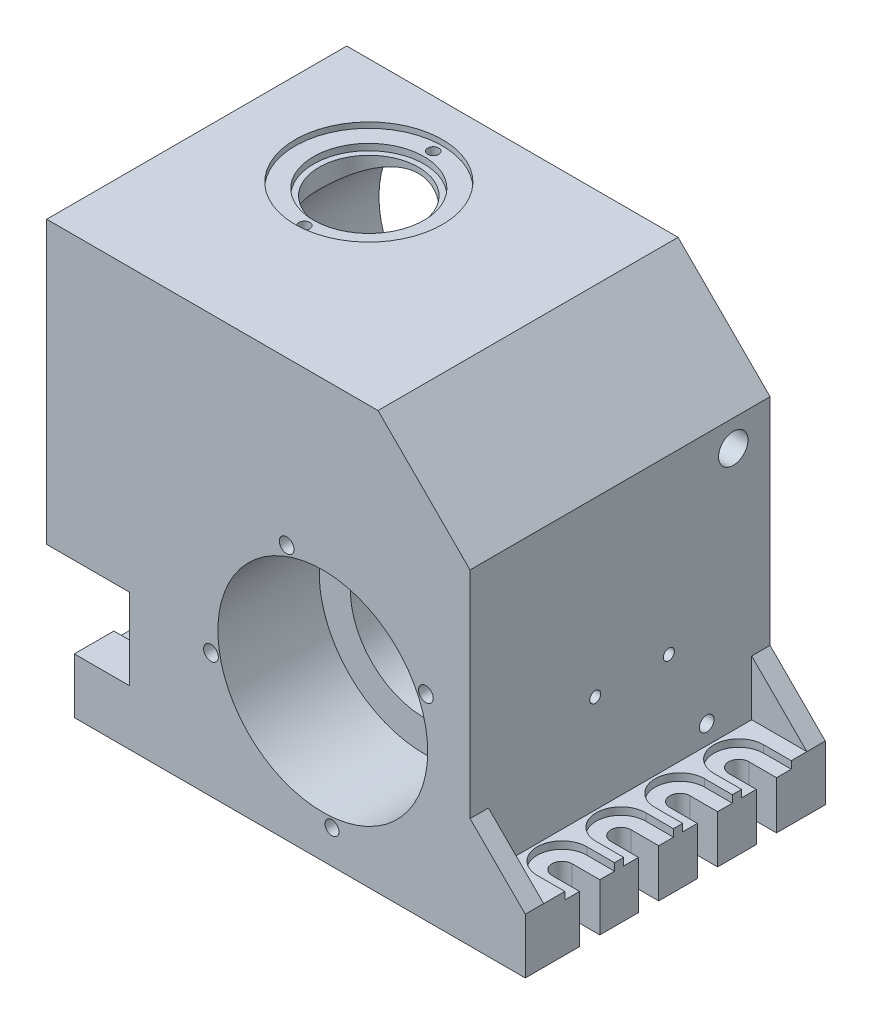
from build123d import *

# Parameters (mm, degrees)
EXTRUDE_1_DEPTH           = 163
SKETCH_2_W                = 143
SKETCH_2_H                = 30
CUT_EXTRUDE_1_DEPTH       = 30
SKETCH_3_W                = 11
SKETCH_3_H                = 30
CUT_EXTRUDE_2_DEPTH       = 15
SKETCH_4_R                = 5.5
CUT_EXTRUDE_3_DEPTH       = 40
CUT_EXTRUDE_4_DEPTH       = 4
SKETCH_6_R                = 40
CUT_EXTRUDE_5_DEPTH       = 248
SKETCH_7_R                = 57
CUT_EXTRUDE_6_DEPTH       = 55
SKETCH_8_R                = 4
SKETCH_8_R_2              = 3.785558093
CUT_EXTRUDE_7_DEPTH       = 18
SKETCH_10_R               = 64.5
CUT_EXTRUDE_8_DEPTH       = 54
SKETCH_11_R               = 42.5
CUT_EXTRUDE_9_DEPTH       = 103
SKETCH_12_R               = 10
CUT_EXTRUDE_10_DEPTH      = 44
SKETCH_13_R               = 21.5
CUT_EXTRUDE_11_DEPTH      = 30
SKETCH_14_R               = 17.5
CUT_EXTRUDE_12_DEPTH      = 11
SKETCH_15_W               = 30
SKETCH_15_H               = 30
EXTRUDE_2_DEPTH           = 163
SKETCH_16_R               = 44.5
CUT_EXTRUDE_13_DEPTH      = 16
SKETCH_17_R               = 52.5
CUT_EXTRUDE_14_DEPTH      = 16
CUT_EXTRUDE_14_DEPTH_BACK = 82
SKETCH_18_R               = 21.5
CUT_EXTRUDE_15_DEPTH      = 29
SKETCH_19_R               = 17.5
CUT_EXTRUDE_16_DEPTH      = 11
SKETCH_20_R               = 10
CUT_EXTRUDE_17_DEPTH      = 3
SKETCH_21_R               = 4
CUT_EXTRUDE_18_DEPTH      = 9
SKETCH_22_R               = 4.14
CUT_EXTRUDE_19_DEPTH      = 10
CUT_EXTRUDE_20_DEPTH      = 120
FILLET_1_R                = 15
SKETCH_24_R               = 27
CUT_EXTRUDE_21_DEPTH      = 30
SKETCH_25_R               = 30
CUT_EXTRUDE_22_DEPTH      = 6.5
SKETCH_26_R               = 40
CUT_EXTRUDE_23_DEPTH      = 3
SKETCH_27_R               = 3
CUT_EXTRUDE_24_DEPTH      = 8
SKETCH_28_R               = 3
CUT_EXTRUDE_25_DEPTH      = 8
SKETCH_29_R               = 4
CUT_EXTRUDE_26_DEPTH      = 37
SKETCH_30_R               = 8
CUT_EXTRUDE_27_DEPTH      = 48


with BuildPart() as part:
    # 草图1 → 凸台-拉伸1 (new body)
    with BuildSketch(Plane.XY):
        Polygon((110, -80), (-105, -80), (-105, -6), (-150, -6), (-150, 147), (30, 147), (80, 97), (80, -20), (110, -50), align=None)
    extrude(amount=EXTRUDE_1_DEPTH)

    # 草图2 → 切除-拉伸1 (cut)
    with BuildSketch(Plane(origin=(110, 0, 0), x_dir=(0, 0, -1), z_dir=(1, 0, 0))):
        with Locations((-81.5, -35)):
            Rectangle(SKETCH_2_W, SKETCH_2_H)
    extrude(amount=-CUT_EXTRUDE_1_DEPTH, mode=Mode.SUBTRACT)

    # 草图3 → 切除-拉伸2 (cut)
    with BuildSketch(Plane(origin=(110, 0, 0), x_dir=(0, 0, -1), z_dir=(1, 0, 0))):
        with Locations((-32, -65)):
            Rectangle(SKETCH_3_W, SKETCH_3_H)
        with Locations((-64, -65)):
            Rectangle(SKETCH_3_W, SKETCH_3_H)
        with Locations((-96, -65)):
            Rectangle(SKETCH_3_W, SKETCH_3_H)
        with Locations((-128, -65)):
            Rectangle(SKETCH_3_W, SKETCH_3_H)
    cut_extrude_2 = extrude(amount=-CUT_EXTRUDE_2_DEPTH, mode=Mode.SUBTRACT)

    # 草图4 → 切除-拉伸3 (cut)
    with BuildSketch(Plane(origin=(0, -50, 0), x_dir=(1, 0, 0), z_dir=(0, 1, 0))):
        with Locations((95, -32)):
            Circle(SKETCH_4_R)
        with Locations((95, -64)):
            Circle(SKETCH_4_R)
        with Locations((95, -96)):
            Circle(SKETCH_4_R)
        with Locations((95, -128)):
            Circle(SKETCH_4_R)
    cut_extrude_3 = extrude(amount=-CUT_EXTRUDE_3_DEPTH, mode=Mode.SUBTRACT)

    # 草图5 → 切除-拉伸4 (cut)
    with BuildSketch(Plane(origin=(0, -50, 0), x_dir=(1, 0, 0), z_dir=(0, 1, 0))):
        with BuildLine():
            Line((95, -77.5), (110, -77.5))
            Line((110, -77.5), (110, -50.5))
            Line((110, -50.5), (95, -50.5))
            ThreePointArc((95, -50.5), (81.5, -64), (95, -77.5))
        make_face()
        with BuildLine():
            Line((95, -45.5), (110, -45.5))
            Line((110, -45.5), (110, -18.5))
            Line((110, -18.5), (95, -18.5))
            ThreePointArc((95, -18.5), (81.5, -32), (95, -45.5))
        make_face()
        with BuildLine():
            Line((95, -109.5), (110, -109.5))
            Line((110, -109.5), (110, -82.5))
            Line((110, -82.5), (95, -82.5))
            ThreePointArc((95, -82.5), (81.5, -96), (95, -109.5))
        make_face()
        with BuildLine():
            Line((95, -141.5), (110, -141.5))
            Line((110, -141.5), (110, -114.5))
            Line((110, -114.5), (95, -114.5))
            ThreePointArc((95, -114.5), (81.5, -128), (95, -141.5))
        make_face()
    cut_extrude_4 = extrude(amount=-CUT_EXTRUDE_4_DEPTH, mode=Mode.SUBTRACT)

    # 草图6 → 切除-拉伸5 (cut)
    with BuildSketch(Plane.XY.offset(163)):
        Circle(SKETCH_6_R)
    extrude(amount=-CUT_EXTRUDE_5_DEPTH, mode=Mode.SUBTRACT)

    # 草图7 → 切除-拉伸6 (cut)
    with BuildSketch(Plane.XY.offset(163)):
        Circle(SKETCH_7_R)
    extrude(amount=-CUT_EXTRUDE_6_DEPTH, mode=Mode.SUBTRACT)

    # 草图8 → 切除-拉伸7 (cut)
    with BuildSketch(Plane.XY.offset(163)):
        with Locations((-19.633415616, 58.809259401)):
            Circle(SKETCH_8_R)
        with Locations((56.013926946, 26.578938807)):
            Circle(SKETCH_8_R)
        with Locations((-60.747020427, -12.401593014)):
            Circle(SKETCH_8_R)
        with Locations((4.98892726, -61.798953104)):
            Circle(SKETCH_8_R_2)
    extrude(amount=-CUT_EXTRUDE_7_DEPTH, mode=Mode.SUBTRACT)

    # 草图10 → 切除-拉伸8 (cut)
    with BuildSketch(Plane(origin=(0, 0, 0), x_dir=(-1, 0, 0), z_dir=(0, 0, -1))):
        Circle(SKETCH_10_R)
    extrude(amount=-CUT_EXTRUDE_8_DEPTH, mode=Mode.SUBTRACT)

    # 草图11 → 切除-拉伸9 (cut)
    with BuildSketch(Plane(origin=(0, 0, 0), x_dir=(-1, 0, 0), z_dir=(0, 0, -1))):
        with Locations((0, 85)):
            Circle(SKETCH_11_R)
    extrude(amount=-CUT_EXTRUDE_9_DEPTH, mode=Mode.SUBTRACT)

    # 草图12 → 切除-拉伸10 (cut)
    with BuildSketch(Plane(origin=(0, 0, 103), x_dir=(-1, 0, 0), z_dir=(0, 0, -1))):
        with Locations((0, 85)):
            Circle(SKETCH_12_R)
    extrude(amount=-CUT_EXTRUDE_10_DEPTH, mode=Mode.SUBTRACT)

    # 草图13 → 切除-拉伸11 (cut)
    with BuildSketch(Plane(origin=(0, 0, 103), x_dir=(-1, 0, 0), z_dir=(0, 0, -1))):
        with Locations((0, 85)):
            Circle(SKETCH_13_R)
    extrude(amount=-CUT_EXTRUDE_11_DEPTH, mode=Mode.SUBTRACT)

    # 草图14 → 切除-拉伸12 (cut)
    with BuildSketch(Plane(origin=(0, 0, 133), x_dir=(-1, 0, 0), z_dir=(0, 0, -1))):
        with Locations((0, 85)):
            Circle(SKETCH_14_R)
    extrude(amount=-CUT_EXTRUDE_12_DEPTH, mode=Mode.SUBTRACT)

    # 草图15 → 凸台-拉伸2 (add)
    with BuildSketch(Plane.XY.offset(163)):
        with Locations((-120, -65)):
            Rectangle(SKETCH_15_W, SKETCH_15_H)
    extrude(amount=-EXTRUDE_2_DEPTH)

    # 镜向1: 切除-拉伸2, 切除-拉伸3, 切除-拉伸4 across plane
    add(cut_extrude_2.mirror(Plane(origin=(-12.5, 0, 0), x_dir=(0, 0, 1), z_dir=(1, 0, 0))), mode=Mode.SUBTRACT)
    add(cut_extrude_3.mirror(Plane(origin=(-12.5, 0, 0), x_dir=(0, 0, 1), z_dir=(1, 0, 0))), mode=Mode.SUBTRACT)
    add(cut_extrude_4.mirror(Plane(origin=(-12.5, 0, 0), x_dir=(0, 0, 1), z_dir=(1, 0, 0))), mode=Mode.SUBTRACT)

    # 草图16 → 切除-拉伸13 (cut)
    with BuildSketch(Plane(origin=(0, 0, 0), x_dir=(-1, 0, 0), z_dir=(0, 0, -1))):
        with Locations((80, 85)):
            Circle(SKETCH_16_R)
    extrude(amount=-CUT_EXTRUDE_13_DEPTH, mode=Mode.SUBTRACT)

    # 草图17 → 切除-拉伸14 (cut, two sides)
    with BuildSketch(Plane(origin=(0, 0, 16), x_dir=(-1, 0, 0), z_dir=(0, 0, -1))) as cut_extrude_14_sk:
        with Locations((80, 85)):
            Circle(SKETCH_17_R)
    extrude(amount=CUT_EXTRUDE_14_DEPTH, mode=Mode.SUBTRACT)
    extrude(cut_extrude_14_sk.sketch, amount=-CUT_EXTRUDE_14_DEPTH_BACK, mode=Mode.SUBTRACT)

    # 草图18 → 切除-拉伸15 (cut)
    with BuildSketch(Plane(origin=(0, 0, 98), x_dir=(-1, 0, 0), z_dir=(0, 0, -1))):
        with Locations((80, 85)):
            Circle(SKETCH_18_R)
    extrude(amount=-CUT_EXTRUDE_15_DEPTH, mode=Mode.SUBTRACT)

    # 草图19 → 切除-拉伸16 (cut)
    with BuildSketch(Plane(origin=(0, 0, 127), x_dir=(-1, 0, 0), z_dir=(0, 0, -1))):
        with Locations((80, 85)):
            Circle(SKETCH_19_R)
    extrude(amount=-CUT_EXTRUDE_16_DEPTH, mode=Mode.SUBTRACT)

    # 草图20 → 切除-拉伸17 (cut)
    with BuildSketch(Plane(origin=(0, 0, 138), x_dir=(-1, 0, 0), z_dir=(0, 0, -1))):
        with Locations((80, 85)):
            Circle(SKETCH_20_R)
    extrude(amount=-CUT_EXTRUDE_17_DEPTH, mode=Mode.SUBTRACT)

    # 草图21 → 切除-拉伸18 (cut)
    with BuildSketch(Plane(origin=(0, 0, 0), x_dir=(-1, 0, 0), z_dir=(0, 0, -1))):
        with Locations((140, 137)):
            Circle(SKETCH_21_R)
        with Locations((95, -65)):
            Circle(SKETCH_21_R)
        with Locations((-70, -65)):
            Circle(SKETCH_21_R)
        with Locations((-70, 87)):
            Circle(SKETCH_21_R)
    extrude(amount=-CUT_EXTRUDE_18_DEPTH, mode=Mode.SUBTRACT)

    # 草图22 → 切除-拉伸19 (cut)
    with BuildSketch(Plane(origin=(0, 0, 0), x_dir=(-1, 0, 0), z_dir=(0, 0, -1))):
        with Locations((140, 4)):
            Circle(SKETCH_22_R)
        with Locations((32, 137)):
            Circle(SKETCH_22_R)
    extrude(amount=-CUT_EXTRUDE_19_DEPTH, mode=Mode.SUBTRACT)

    # 草图23 → 切除-拉伸20 (cut)
    with BuildSketch(Plane(origin=(0, 0, 54), x_dir=(-1, 0, 0), z_dir=(0, 0, -1))):
        Polygon((29.3557979, 34.151039122), (59.493224011, 64.288465232), (34.663329643, 89.1183596), (14.458781088, 44.995191065), align=None)
    extrude(amount=CUT_EXTRUDE_20_DEPTH, mode=Mode.SUBTRACT)

    # 圆角1
    fillet_1_edges = [part.edges().sort_by_distance(p)[0] for p in [
        (31.388834989, 56.347058824, 27),
        (-34.0625, 59.583546791, 76),
        (-34.0625, 110.416453209, 49),
        (-47.019201536, 44.152516201, 27),
    ]]
    fillet(fillet_1_edges, radius=FILLET_1_R)

    # 草图24 → 切除-拉伸21 (cut)
    with BuildSketch(Plane(origin=(0, 147, 0), x_dir=(1, 0, 0), z_dir=(0, 1, 0))):
        with Locations((-80, -58)):
            Circle(SKETCH_24_R)
    extrude(amount=-CUT_EXTRUDE_21_DEPTH, mode=Mode.SUBTRACT)

    # 草图25 → 切除-拉伸22 (cut)
    with BuildSketch(Plane(origin=(0, 147, 0), x_dir=(1, 0, 0), z_dir=(0, 1, 0))):
        with Locations((-80, -58)):
            Circle(SKETCH_25_R)
    extrude(amount=-CUT_EXTRUDE_22_DEPTH, mode=Mode.SUBTRACT)

    # 草图26 → 切除-拉伸23 (cut)
    with BuildSketch(Plane(origin=(0, 147, 0), x_dir=(1, 0, 0), z_dir=(0, 1, 0))):
        with Locations((-80, -58)):
            Circle(SKETCH_26_R)
    extrude(amount=-CUT_EXTRUDE_23_DEPTH, mode=Mode.SUBTRACT)

    # 草图27 → 切除-拉伸24 (cut)
    with BuildSketch(Plane(origin=(0, 144, 0), x_dir=(1, 0, 0), z_dir=(0, 1, 0))):
        with Locations((-80, -23)):
            Circle(SKETCH_27_R)
        with Locations((-80, -93)):
            Circle(SKETCH_27_R)
    extrude(amount=-CUT_EXTRUDE_24_DEPTH, mode=Mode.SUBTRACT)

    # 草图28 → 切除-拉伸25 (cut)
    with BuildSketch(Plane(origin=(80, 0, 0), x_dir=(0, 0, -1), z_dir=(1, 0, 0))):
        with Locations((-95, 3.23)):
            Circle(SKETCH_28_R)
        with Locations((-55, 3.23)):
            Circle(SKETCH_28_R)
    extrude(amount=-CUT_EXTRUDE_25_DEPTH, mode=Mode.SUBTRACT)

    # 草图29 → 切除-拉伸26 (cut)
    with BuildSketch(Plane(origin=(80, 0, 0), x_dir=(0, 0, -1), z_dir=(1, 0, 0))):
        with Locations((-34.434348245, -39.57044591)):
            Circle(SKETCH_29_R)
    extrude(amount=-CUT_EXTRUDE_26_DEPTH, mode=Mode.SUBTRACT)

    # 草图30 → 切除-拉伸27 (cut)
    with BuildSketch(Plane(origin=(80, 0, 0), x_dir=(0, 0, -1), z_dir=(1, 0, 0))):
        with Locations((-20, 82.705301822)):
            Circle(SKETCH_30_R)
    extrude(amount=-CUT_EXTRUDE_27_DEPTH, mode=Mode.SUBTRACT)


solid = part.part
